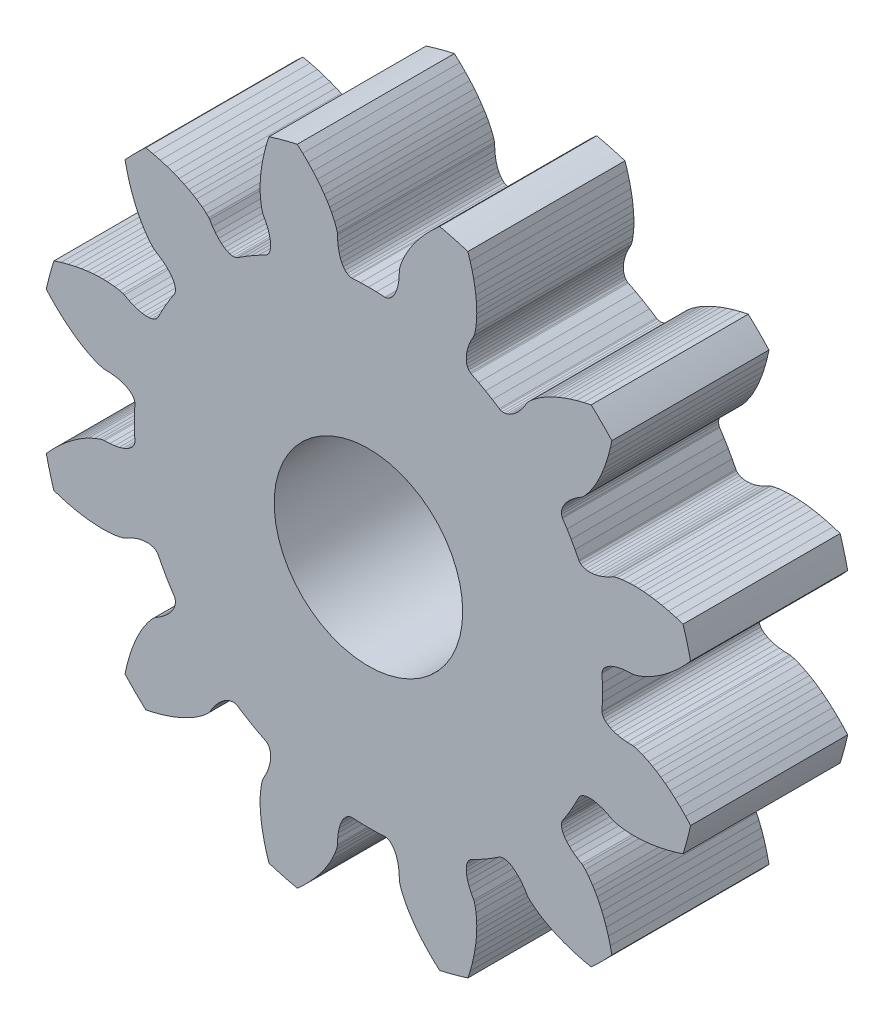
from build123d import *

# Parameters (mm, degrees)
SZKIC_R                     = 3
DODANIE_WYCI_GNI_CIE1_DEPTH = 5


with BuildPart() as part:
    # szkic → Dodanie-wyciągnięcie1 (new body)
    with BuildSketch(Plane.XY):
        with BuildLine():
            Line((13.3041035, -6.8561363), (13.3646303, -6.6242917))
            Line((13.3646303, -6.6242917), (13.4304655, -6.4093816))
            Line((13.4304655, -6.4093816), (13.5002922, -6.2114851))
            Line((13.5002922, -6.2114851), (13.5727071, -6.0307313))
            Line((13.5727071, -6.0307313), (13.646359, -5.8670802))
            Line((13.646359, -5.8670802), (13.721124, -5.718017))
            Line((13.721124, -5.718017), (13.7934881, -5.5876952))
            Line((13.7934881, -5.5876952), (13.8641894, -5.4719934))
            Line((13.8641894, -5.4719934), (13.993399, -5.287051))
            Line((13.993399, -5.287051), (14.1005731, -5.157982))
            Line((14.1005731, -5.157982), (14.1765304, -5.080584))
            Line((14.1765304, -5.080584), (14.2152558, -5.0521983))
            Line((14.2152558, -5.0521983), (14.3621288, -4.9615699))
            Line((14.3621288, -4.9615699), (14.4896324, -4.8681526))
            Line((14.4896324, -4.8681526), (14.5978226, -4.7734035))
            Line((14.5978226, -4.7734035), (14.6868312, -4.6787708))
            Line((14.6868312, -4.6787708), (14.7568878, -4.5856924))
            Line((14.7568878, -4.5856924), (14.8083, -4.495561))
            Line((14.8083, -4.495561), (14.8414711, -4.409795))
            Line((14.8414711, -4.409795), (14.8568795, -4.3297232))
            Line((14.8568795, -4.3297232), (14.8550807, -4.2566876))
            Line((14.8550807, -4.2566876), (14.8367255, -4.1919755))
            Line((14.8367255, -4.1919755), (14.821549, -4.163129))
            Line((14.821549, -4.163129), (14.6787997, -3.9427598))
            Line((14.6787997, -3.9427598), (14.5481107, -3.725))
            Line((14.5481107, -3.725), (14.4248697, -3.5029402))
            Line((14.4248697, -3.5029402), (14.305399, -3.269131))
            Line((14.305399, -3.269131), (14.2880055, -3.2415645))
            Line((14.2880055, -3.2415645), (14.2411407, -3.1933124))
            Line((14.2411407, -3.1933124), (14.1787895, -3.1552368))
            Line((14.1787895, -3.1552368), (14.1017411, -3.128545))
            Line((14.1017411, -3.128545), (14.01088, -3.114389))
            Line((14.01088, -3.114389), (13.9071178, -3.1138476))
            Line((13.9071178, -3.1138476), (13.7914812, -3.1279792))
            Line((13.7914812, -3.1279792), (13.6650226, -3.1577465))
            Line((13.6650226, -3.1577465), (13.5288724, -3.2040674))
            Line((13.5288724, -3.2040674), (13.3842188, -3.2677801))
            Line((13.3842188, -3.2677801), (13.2322958, -3.3496617))
            Line((13.2322958, -3.3496617), (13.1883504, -3.369006))
            Line((13.1883504, -3.369006), (13.0833431, -3.396088))
            Line((13.0833431, -3.396088), (12.917979, -3.424369))
            Line((12.917979, -3.424369), (12.6932094, -3.4437966))
            Line((12.6932094, -3.4437966), (12.5576581, -3.4471748))
            Line((12.5576581, -3.4471748), (12.408614, -3.444683))
            Line((12.408614, -3.444683), (12.242139, -3.4348998))
            Line((12.242139, -3.4348998), (12.0635871, -3.4168587))
            Line((12.0635871, -3.4168587), (11.8708422, -3.3891949))
            Line((11.8708422, -3.3891949), (11.6645455, -3.3507184))
            Line((11.6645455, -3.3507184), (11.4455103, -3.3002783))
            Line((11.4455103, -3.3002783), (11.2144635, -3.2367737))
            Line((11.2144635, -3.2367737), (10.9882086, -3.1643386))
            ThreePointArc((10.9882086, -3.1643386), (10.857824593, -2.717587715), (10.747365, -2.2654981))
            Line((10.747365, -2.2654981), (10.90709, -2.08964))
            Line((10.90709, -2.08964), (11.07543, -1.91912))
            Line((11.07543, -1.91912), (11.2399, -1.76592))
            Line((11.2399, -1.76592), (11.39932, -1.62945))
            Line((11.39932, -1.62945), (11.55241, -1.50912))
            Line((11.55241, -1.50912), (11.69802, -1.40422))
            Line((11.69802, -1.40422), (11.8373, -1.31251))
            Line((11.8373, -1.31251), (11.96513, -1.23583))
            Line((11.96513, -1.23583), (12.08421, -1.17098))
            Line((12.08421, -1.17098), (12.28858, -1.07542))
            Line((12.28858, -1.07542), (12.44593, -1.01723))
            Line((12.44593, -1.01723), (12.55041, -0.98818))
            Line((12.55041, -0.98818), (12.59814, -0.98296))
            Line((12.59814, -0.98296), (12.77065, -0.97791))
            Line((12.77065, -0.97791), (12.92778, -0.96076))
            Line((12.92778, -0.96076), (13.06885, -0.9328))
            Line((13.06885, -0.9328), (13.19325, -0.89535))
            Line((13.19325, -0.89535), (13.30046, -0.84977))
            Line((13.30046, -0.84977), (13.39005, -0.79742))
            Line((13.39005, -0.79742), (13.46166, -0.73973))
            Line((13.46166, -0.73973), (13.51504, -0.67809))
            Line((13.51504, -0.67809), (13.55, -0.61394))
            Line((13.55, -0.61394), (13.56646, -0.54872))
            Line((13.56646, -0.54872), (13.56774, -0.51615))
            Line((13.56774, -0.51615), (13.5543, -0.25393))
            Line((13.5543, -0.25393), (13.55, 0))
            Line((13.55, 0), (13.5543, 0.25393))
            Line((13.5543, 0.25393), (13.56774, 0.51615))
            Line((13.56774, 0.51615), (13.56646, 0.54872))
            Line((13.56646, 0.54872), (13.55, 0.61394))
            Line((13.55, 0.61394), (13.51504, 0.67809))
            Line((13.51504, 0.67809), (13.46166, 0.73973))
            Line((13.46166, 0.73973), (13.39005, 0.79742))
            Line((13.39005, 0.79742), (13.30046, 0.84977))
            Line((13.30046, 0.84977), (13.19325, 0.89535))
            Line((13.19325, 0.89535), (13.06885, 0.9328))
            Line((13.06885, 0.9328), (12.92778, 0.96076))
            Line((12.92778, 0.96076), (12.77065, 0.97791))
            Line((12.77065, 0.97791), (12.59814, 0.98296))
            Line((12.59814, 0.98296), (12.55041, 0.98818))
            Line((12.55041, 0.98818), (12.44593, 1.01723))
            Line((12.44593, 1.01723), (12.28858, 1.07542))
            Line((12.28858, 1.07542), (12.08421, 1.17098))
            Line((12.08421, 1.17098), (11.96513, 1.23583))
            Line((11.96513, 1.23583), (11.8373, 1.31251))
            Line((11.8373, 1.31251), (11.69802, 1.40422))
            Line((11.69802, 1.40422), (11.55241, 1.50912))
            Line((11.55241, 1.50912), (11.39932, 1.62945))
            Line((11.39932, 1.62945), (11.2399, 1.76592))
            Line((11.2399, 1.76592), (11.07543, 1.91912))
            Line((11.07543, 1.91912), (10.90709, 2.08964))
            Line((10.90709, 2.08964), (10.747365, 2.2654981))
            ThreePointArc((10.747365, 2.2654981), (10.857824593, 2.717587715), (10.9882086, 3.1643386))
            Line((10.9882086, 3.1643386), (11.2144635, 3.2367737))
            Line((11.2144635, 3.2367737), (11.4455103, 3.3002783))
            Line((11.4455103, 3.3002783), (11.6645455, 3.3507184))
            Line((11.6645455, 3.3507184), (11.8708422, 3.3891949))
            Line((11.8708422, 3.3891949), (12.0635871, 3.4168587))
            Line((12.0635871, 3.4168587), (12.242139, 3.4348998))
            Line((12.242139, 3.4348998), (12.408614, 3.444683))
            Line((12.408614, 3.444683), (12.5576581, 3.4471748))
            Line((12.5576581, 3.4471748), (12.6932094, 3.4437966))
            Line((12.6932094, 3.4437966), (12.917979, 3.424369))
            Line((12.917979, 3.424369), (13.0833431, 3.396088))
            Line((13.0833431, 3.396088), (13.1883504, 3.369006))
            Line((13.1883504, 3.369006), (13.2322958, 3.3496617))
            Line((13.2322958, 3.3496617), (13.3842188, 3.2677801))
            Line((13.3842188, 3.2677801), (13.5288724, 3.2040674))
            Line((13.5288724, 3.2040674), (13.6650226, 3.1577465))
            Line((13.6650226, 3.1577465), (13.7914812, 3.1279792))
            Line((13.7914812, 3.1279792), (13.9071178, 3.1138476))
            Line((13.9071178, 3.1138476), (14.01088, 3.114389))
            Line((14.01088, 3.114389), (14.1017411, 3.128545))
            Line((14.1017411, 3.128545), (14.1787895, 3.1552368))
            Line((14.1787895, 3.1552368), (14.2411407, 3.1933124))
            Line((14.2411407, 3.1933124), (14.2880055, 3.2415645))
            Line((14.2880055, 3.2415645), (14.305399, 3.269131))
            Line((14.305399, 3.269131), (14.4248697, 3.5029402))
            Line((14.4248697, 3.5029402), (14.5481107, 3.725))
            Line((14.5481107, 3.725), (14.6787997, 3.9427598))
            Line((14.6787997, 3.9427598), (14.821549, 4.163129))
            Line((14.821549, 4.163129), (14.8367255, 4.1919755))
            Line((14.8367255, 4.1919755), (14.8550807, 4.2566876))
            Line((14.8550807, 4.2566876), (14.8568795, 4.3297232))
            Line((14.8568795, 4.3297232), (14.8414711, 4.409795))
            Line((14.8414711, 4.409795), (14.8083, 4.495561))
            Line((14.8083, 4.495561), (14.7568878, 4.5856924))
            Line((14.7568878, 4.5856924), (14.6868312, 4.6787708))
            Line((14.6868312, 4.6787708), (14.5978226, 4.7734035))
            Line((14.5978226, 4.7734035), (14.4896324, 4.8681526))
            Line((14.4896324, 4.8681526), (14.3621288, 4.9615699))
            Line((14.3621288, 4.9615699), (14.2152558, 5.0521983))
            Line((14.2152558, 5.0521983), (14.1765304, 5.080584))
            Line((14.1765304, 5.080584), (14.1005731, 5.157982))
            Line((14.1005731, 5.157982), (13.993399, 5.287051))
            Line((13.993399, 5.287051), (13.8641894, 5.4719934))
            Line((13.8641894, 5.4719934), (13.7934881, 5.5876952))
            Line((13.7934881, 5.5876952), (13.721124, 5.718017))
            Line((13.721124, 5.718017), (13.646359, 5.8670802))
            Line((13.646359, 5.8670802), (13.5727071, 6.0307313))
            Line((13.5727071, 6.0307313), (13.5002922, 6.2114851))
            Line((13.5002922, 6.2114851), (13.4304655, 6.4093816))
            Line((13.4304655, 6.4093816), (13.3646303, 6.6242917))
            Line((13.3646303, 6.6242917), (13.3041035, 6.8561363))
            Line((13.3041035, 6.8561363), (13.2537067, 7.0882964))
            ThreePointArc((13.2537067, 7.0882964), (13.575412309, 7.424587691), (13.9117036, 7.7462933))
            Line((13.9117036, 7.7462933), (14.1438637, 7.6958965))
            Line((14.1438637, 7.6958965), (14.3757083, 7.6353697))
            Line((14.3757083, 7.6353697), (14.5906184, 7.5695345))
            Line((14.5906184, 7.5695345), (14.7885149, 7.4997078))
            Line((14.7885149, 7.4997078), (14.9692687, 7.4272929))
            Line((14.9692687, 7.4272929), (15.1329198, 7.353641))
            Line((15.1329198, 7.353641), (15.281983, 7.278876))
            Line((15.281983, 7.278876), (15.4123048, 7.2065119))
            Line((15.4123048, 7.2065119), (15.5280066, 7.1358106))
            Line((15.5280066, 7.1358106), (15.712949, 7.006601))
            Line((15.712949, 7.006601), (15.842018, 6.8994269))
            Line((15.842018, 6.8994269), (15.919416, 6.8234696))
            Line((15.919416, 6.8234696), (15.9478017, 6.7847442))
            Line((15.9478017, 6.7847442), (16.0384301, 6.6378712))
            Line((16.0384301, 6.6378712), (16.1318474, 6.5103676))
            Line((16.1318474, 6.5103676), (16.2265965, 6.4021774))
            Line((16.2265965, 6.4021774), (16.3212292, 6.3131688))
            Line((16.3212292, 6.3131688), (16.4143076, 6.2431122))
            Line((16.4143076, 6.2431122), (16.504439, 6.1917))
            Line((16.504439, 6.1917), (16.590205, 6.1585289))
            Line((16.590205, 6.1585289), (16.6702768, 6.1431205))
            Line((16.6702768, 6.1431205), (16.7433124, 6.1449193))
            Line((16.7433124, 6.1449193), (16.8080245, 6.1632745))
            Line((16.8080245, 6.1632745), (16.836871, 6.178451))
            Line((16.836871, 6.178451), (17.0572402, 6.3212003))
            Line((17.0572402, 6.3212003), (17.275, 6.4518893))
            Line((17.275, 6.4518893), (17.4970598, 6.5751303))
            Line((17.4970598, 6.5751303), (17.730869, 6.694601))
            Line((17.730869, 6.694601), (17.7584355, 6.7119945))
            Line((17.7584355, 6.7119945), (17.8066876, 6.7588593))
            Line((17.8066876, 6.7588593), (17.8447632, 6.8212105))
            Line((17.8447632, 6.8212105), (17.871455, 6.8982589))
            Line((17.871455, 6.8982589), (17.885611, 6.98912))
            Line((17.885611, 6.98912), (17.8861524, 7.0928822))
            Line((17.8861524, 7.0928822), (17.8720208, 7.2085188))
            Line((17.8720208, 7.2085188), (17.8422535, 7.3349774))
            Line((17.8422535, 7.3349774), (17.7959326, 7.4711276))
            Line((17.7959326, 7.4711276), (17.7322199, 7.6157812))
            Line((17.7322199, 7.6157812), (17.6503383, 7.7677042))
            Line((17.6503383, 7.7677042), (17.630994, 7.8116496))
            Line((17.630994, 7.8116496), (17.603912, 7.9166569))
            Line((17.603912, 7.9166569), (17.575631, 8.082021))
            Line((17.575631, 8.082021), (17.5562034, 8.3067906))
            Line((17.5562034, 8.3067906), (17.5528252, 8.4423419))
            Line((17.5528252, 8.4423419), (17.555317, 8.591386))
            Line((17.555317, 8.591386), (17.5651002, 8.757861))
            Line((17.5651002, 8.757861), (17.5831413, 8.9364129))
            Line((17.5831413, 8.9364129), (17.6108051, 9.1291578))
            Line((17.6108051, 9.1291578), (17.6492816, 9.3354545))
            Line((17.6492816, 9.3354545), (17.6997217, 9.5544897))
            Line((17.6997217, 9.5544897), (17.7632263, 9.7855365))
            Line((17.7632263, 9.7855365), (17.8356614, 10.0117914))
            ThreePointArc((17.8356614, 10.0117914), (18.282412285, 10.142175407), (18.7345019, 10.252635))
            Line((18.7345019, 10.252635), (18.91036, 10.09291))
            Line((18.91036, 10.09291), (19.08088, 9.92457))
            Line((19.08088, 9.92457), (19.23408, 9.7601))
            Line((19.23408, 9.7601), (19.37055, 9.60068))
            Line((19.37055, 9.60068), (19.49088, 9.44759))
            Line((19.49088, 9.44759), (19.59578, 9.30198))
            Line((19.59578, 9.30198), (19.68749, 9.1627))
            Line((19.68749, 9.1627), (19.76417, 9.03487))
            Line((19.76417, 9.03487), (19.82902, 8.91579))
            Line((19.82902, 8.91579), (19.92458, 8.71142))
            Line((19.92458, 8.71142), (19.98277, 8.55407))
            Line((19.98277, 8.55407), (20.01182, 8.44959))
            Line((20.01182, 8.44959), (20.01704, 8.40186))
            Line((20.01704, 8.40186), (20.02209, 8.22935))
            Line((20.02209, 8.22935), (20.03924, 8.07222))
            Line((20.03924, 8.07222), (20.0672, 7.93115))
            Line((20.0672, 7.93115), (20.10465, 7.80675))
            Line((20.10465, 7.80675), (20.15023, 7.69954))
            Line((20.15023, 7.69954), (20.20258, 7.60995))
            Line((20.20258, 7.60995), (20.26027, 7.53834))
            Line((20.26027, 7.53834), (20.32191, 7.48496))
            Line((20.32191, 7.48496), (20.38606, 7.45))
            Line((20.38606, 7.45), (20.45128, 7.43354))
            Line((20.45128, 7.43354), (20.48385, 7.43226))
            Line((20.48385, 7.43226), (20.74607, 7.4457))
            Line((20.74607, 7.4457), (21, 7.45))
            Line((21, 7.45), (21.25393, 7.4457))
            Line((21.25393, 7.4457), (21.51615, 7.43226))
            Line((21.51615, 7.43226), (21.54872, 7.43354))
            Line((21.54872, 7.43354), (21.61394, 7.45))
            Line((21.61394, 7.45), (21.67809, 7.48496))
            Line((21.67809, 7.48496), (21.73973, 7.53834))
            Line((21.73973, 7.53834), (21.79742, 7.60995))
            Line((21.79742, 7.60995), (21.84977, 7.69954))
            Line((21.84977, 7.69954), (21.89535, 7.80675))
            Line((21.89535, 7.80675), (21.9328, 7.93115))
            Line((21.9328, 7.93115), (21.96076, 8.07222))
            Line((21.96076, 8.07222), (21.97791, 8.22935))
            Line((21.97791, 8.22935), (21.98296, 8.40186))
            Line((21.98296, 8.40186), (21.98818, 8.44959))
            Line((21.98818, 8.44959), (22.01723, 8.55407))
            Line((22.01723, 8.55407), (22.07542, 8.71142))
            Line((22.07542, 8.71142), (22.17098, 8.91579))
            Line((22.17098, 8.91579), (22.23583, 9.03487))
            Line((22.23583, 9.03487), (22.31251, 9.1627))
            Line((22.31251, 9.1627), (22.40422, 9.30198))
            Line((22.40422, 9.30198), (22.50912, 9.44759))
            Line((22.50912, 9.44759), (22.62945, 9.60068))
            Line((22.62945, 9.60068), (22.76592, 9.7601))
            Line((22.76592, 9.7601), (22.91912, 9.92457))
            Line((22.91912, 9.92457), (23.08964, 10.09291))
            Line((23.08964, 10.09291), (23.2654981, 10.252635))
            ThreePointArc((23.2654981, 10.252635), (23.717587715, 10.142175407), (24.1643386, 10.0117914))
            Line((24.1643386, 10.0117914), (24.2367737, 9.7855365))
            Line((24.2367737, 9.7855365), (24.3002783, 9.5544897))
            Line((24.3002783, 9.5544897), (24.3507184, 9.3354545))
            Line((24.3507184, 9.3354545), (24.3891949, 9.1291578))
            Line((24.3891949, 9.1291578), (24.4168587, 8.9364129))
            Line((24.4168587, 8.9364129), (24.4348998, 8.757861))
            Line((24.4348998, 8.757861), (24.444683, 8.591386))
            Line((24.444683, 8.591386), (24.4471748, 8.4423419))
            Line((24.4471748, 8.4423419), (24.4437966, 8.3067906))
            Line((24.4437966, 8.3067906), (24.424369, 8.082021))
            Line((24.424369, 8.082021), (24.396088, 7.9166569))
            Line((24.396088, 7.9166569), (24.369006, 7.8116496))
            Line((24.369006, 7.8116496), (24.3496617, 7.7677042))
            Line((24.3496617, 7.7677042), (24.2677801, 7.6157812))
            Line((24.2677801, 7.6157812), (24.2040674, 7.4711276))
            Line((24.2040674, 7.4711276), (24.1577465, 7.3349774))
            Line((24.1577465, 7.3349774), (24.1279792, 7.2085188))
            Line((24.1279792, 7.2085188), (24.1138476, 7.0928822))
            Line((24.1138476, 7.0928822), (24.114389, 6.98912))
            Line((24.114389, 6.98912), (24.128545, 6.8982589))
            Line((24.128545, 6.8982589), (24.1552368, 6.8212105))
            Line((24.1552368, 6.8212105), (24.1933124, 6.7588593))
            Line((24.1933124, 6.7588593), (24.2415645, 6.7119945))
            Line((24.2415645, 6.7119945), (24.269131, 6.694601))
            Line((24.269131, 6.694601), (24.5029402, 6.5751303))
            Line((24.5029402, 6.5751303), (24.725, 6.4518893))
            Line((24.725, 6.4518893), (24.9427598, 6.3212003))
            Line((24.9427598, 6.3212003), (25.163129, 6.178451))
            Line((25.163129, 6.178451), (25.1919755, 6.1632745))
            Line((25.1919755, 6.1632745), (25.2566876, 6.1449193))
            Line((25.2566876, 6.1449193), (25.3297232, 6.1431205))
            Line((25.3297232, 6.1431205), (25.409795, 6.1585289))
            Line((25.409795, 6.1585289), (25.495561, 6.1917))
            Line((25.495561, 6.1917), (25.5856924, 6.2431122))
            Line((25.5856924, 6.2431122), (25.6787708, 6.3131688))
            Line((25.6787708, 6.3131688), (25.7734035, 6.4021774))
            Line((25.7734035, 6.4021774), (25.8681526, 6.5103676))
            Line((25.8681526, 6.5103676), (25.9615699, 6.6378712))
            Line((25.9615699, 6.6378712), (26.0521983, 6.7847442))
            Line((26.0521983, 6.7847442), (26.080584, 6.8234696))
            Line((26.080584, 6.8234696), (26.157982, 6.8994269))
            Line((26.157982, 6.8994269), (26.287051, 7.006601))
            Line((26.287051, 7.006601), (26.4719934, 7.1358106))
            Line((26.4719934, 7.1358106), (26.5876952, 7.2065119))
            Line((26.5876952, 7.2065119), (26.718017, 7.278876))
            Line((26.718017, 7.278876), (26.8670802, 7.353641))
            Line((26.8670802, 7.353641), (27.0307313, 7.4272929))
            Line((27.0307313, 7.4272929), (27.2114851, 7.4997078))
            Line((27.2114851, 7.4997078), (27.4093816, 7.5695345))
            Line((27.4093816, 7.5695345), (27.6242917, 7.6353697))
            Line((27.6242917, 7.6353697), (27.8561363, 7.6958965))
            Line((27.8561363, 7.6958965), (28.0882964, 7.7462933))
            ThreePointArc((28.0882964, 7.7462933), (28.424587691, 7.424587691), (28.7462933, 7.0882964))
            Line((28.7462933, 7.0882964), (28.6958965, 6.8561363))
            Line((28.6958965, 6.8561363), (28.6353697, 6.6242917))
            Line((28.6353697, 6.6242917), (28.5695345, 6.4093816))
            Line((28.5695345, 6.4093816), (28.4997078, 6.2114851))
            Line((28.4997078, 6.2114851), (28.4272929, 6.0307313))
            Line((28.4272929, 6.0307313), (28.353641, 5.8670802))
            Line((28.353641, 5.8670802), (28.278876, 5.718017))
            Line((28.278876, 5.718017), (28.2065119, 5.5876952))
            Line((28.2065119, 5.5876952), (28.1358106, 5.4719934))
            Line((28.1358106, 5.4719934), (28.006601, 5.287051))
            Line((28.006601, 5.287051), (27.8994269, 5.157982))
            Line((27.8994269, 5.157982), (27.8234696, 5.080584))
            Line((27.8234696, 5.080584), (27.7847442, 5.0521983))
            Line((27.7847442, 5.0521983), (27.6378712, 4.9615699))
            Line((27.6378712, 4.9615699), (27.5103676, 4.8681526))
            Line((27.5103676, 4.8681526), (27.4021774, 4.7734035))
            Line((27.4021774, 4.7734035), (27.3131688, 4.6787708))
            Line((27.3131688, 4.6787708), (27.2431122, 4.5856924))
            Line((27.2431122, 4.5856924), (27.1917, 4.495561))
            Line((27.1917, 4.495561), (27.1585289, 4.409795))
            Line((27.1585289, 4.409795), (27.1431205, 4.3297232))
            Line((27.1431205, 4.3297232), (27.1449193, 4.2566876))
            Line((27.1449193, 4.2566876), (27.1632745, 4.1919755))
            Line((27.1632745, 4.1919755), (27.178451, 4.163129))
            Line((27.178451, 4.163129), (27.3212003, 3.9427598))
            Line((27.3212003, 3.9427598), (27.4518893, 3.725))
            Line((27.4518893, 3.725), (27.5751303, 3.5029402))
            Line((27.5751303, 3.5029402), (27.694601, 3.269131))
            Line((27.694601, 3.269131), (27.7119945, 3.2415645))
            Line((27.7119945, 3.2415645), (27.7588593, 3.1933124))
            Line((27.7588593, 3.1933124), (27.8212105, 3.1552368))
            Line((27.8212105, 3.1552368), (27.8982589, 3.128545))
            Line((27.8982589, 3.128545), (27.98912, 3.114389))
            Line((27.98912, 3.114389), (28.0928822, 3.1138476))
            Line((28.0928822, 3.1138476), (28.2085188, 3.1279792))
            Line((28.2085188, 3.1279792), (28.3349774, 3.1577465))
            Line((28.3349774, 3.1577465), (28.4711276, 3.2040674))
            Line((28.4711276, 3.2040674), (28.6157812, 3.2677801))
            Line((28.6157812, 3.2677801), (28.7677042, 3.3496617))
            Line((28.7677042, 3.3496617), (28.8116496, 3.369006))
            Line((28.8116496, 3.369006), (28.9166569, 3.396088))
            Line((28.9166569, 3.396088), (29.082021, 3.424369))
            Line((29.082021, 3.424369), (29.3067906, 3.4437966))
            Line((29.3067906, 3.4437966), (29.4423419, 3.4471748))
            Line((29.4423419, 3.4471748), (29.591386, 3.444683))
            Line((29.591386, 3.444683), (29.757861, 3.4348998))
            Line((29.757861, 3.4348998), (29.9364129, 3.4168587))
            Line((29.9364129, 3.4168587), (30.1291578, 3.3891949))
            Line((30.1291578, 3.3891949), (30.3354545, 3.3507184))
            Line((30.3354545, 3.3507184), (30.5544897, 3.3002783))
            Line((30.5544897, 3.3002783), (30.7855365, 3.2367737))
            Line((30.7855365, 3.2367737), (31.0117914, 3.1643386))
            ThreePointArc((31.0117914, 3.1643386), (31.142175407, 2.717587715), (31.252635, 2.2654981))
            Line((31.252635, 2.2654981), (31.09291, 2.08964))
            Line((31.09291, 2.08964), (30.92457, 1.91912))
            Line((30.92457, 1.91912), (30.7601, 1.76592))
            Line((30.7601, 1.76592), (30.60068, 1.62945))
            Line((30.60068, 1.62945), (30.44759, 1.50912))
            Line((30.44759, 1.50912), (30.30198, 1.40422))
            Line((30.30198, 1.40422), (30.1627, 1.31251))
            Line((30.1627, 1.31251), (30.03487, 1.23583))
            Line((30.03487, 1.23583), (29.91579, 1.17098))
            Line((29.91579, 1.17098), (29.71142, 1.07542))
            Line((29.71142, 1.07542), (29.55407, 1.01723))
            Line((29.55407, 1.01723), (29.44959, 0.98818))
            Line((29.44959, 0.98818), (29.40186, 0.98296))
            Line((29.40186, 0.98296), (29.22935, 0.97791))
            Line((29.22935, 0.97791), (29.07222, 0.96076))
            Line((29.07222, 0.96076), (28.93115, 0.9328))
            Line((28.93115, 0.9328), (28.80675, 0.89535))
            Line((28.80675, 0.89535), (28.69954, 0.84977))
            Line((28.69954, 0.84977), (28.60995, 0.79742))
            Line((28.60995, 0.79742), (28.53834, 0.73973))
            Line((28.53834, 0.73973), (28.48496, 0.67809))
            Line((28.48496, 0.67809), (28.45, 0.61394))
            Line((28.45, 0.61394), (28.43354, 0.54872))
            Line((28.43354, 0.54872), (28.43226, 0.51615))
            Line((28.43226, 0.51615), (28.4457, 0.25393))
            Line((28.4457, 0.25393), (28.45, 0))
            Line((28.45, 0), (28.4457, -0.25393))
            Line((28.4457, -0.25393), (28.43226, -0.51615))
            Line((28.43226, -0.51615), (28.43354, -0.54872))
            Line((28.43354, -0.54872), (28.45, -0.61394))
            Line((28.45, -0.61394), (28.48496, -0.67809))
            Line((28.48496, -0.67809), (28.53834, -0.73973))
            Line((28.53834, -0.73973), (28.60995, -0.79742))
            Line((28.60995, -0.79742), (28.69954, -0.84977))
            Line((28.69954, -0.84977), (28.80675, -0.89535))
            Line((28.80675, -0.89535), (28.93115, -0.9328))
            Line((28.93115, -0.9328), (29.07222, -0.96076))
            Line((29.07222, -0.96076), (29.22935, -0.97791))
            Line((29.22935, -0.97791), (29.40186, -0.98296))
            Line((29.40186, -0.98296), (29.44959, -0.98818))
            Line((29.44959, -0.98818), (29.55407, -1.01723))
            Line((29.55407, -1.01723), (29.71142, -1.07542))
            Line((29.71142, -1.07542), (29.91579, -1.17098))
            Line((29.91579, -1.17098), (30.03487, -1.23583))
            Line((30.03487, -1.23583), (30.1627, -1.31251))
            Line((30.1627, -1.31251), (30.30198, -1.40422))
            Line((30.30198, -1.40422), (30.44759, -1.50912))
            Line((30.44759, -1.50912), (30.60068, -1.62945))
            Line((30.60068, -1.62945), (30.7601, -1.76592))
            Line((30.7601, -1.76592), (30.92457, -1.91912))
            Line((30.92457, -1.91912), (31.09291, -2.08964))
            Line((31.09291, -2.08964), (31.252635, -2.2654981))
            ThreePointArc((31.252635, -2.2654981), (31.142175407, -2.717587715), (31.0117914, -3.1643386))
            Line((31.0117914, -3.1643386), (30.7855365, -3.2367737))
            Line((30.7855365, -3.2367737), (30.5544897, -3.3002783))
            Line((30.5544897, -3.3002783), (30.3354545, -3.3507184))
            Line((30.3354545, -3.3507184), (30.1291578, -3.3891949))
            Line((30.1291578, -3.3891949), (29.9364129, -3.4168587))
            Line((29.9364129, -3.4168587), (29.757861, -3.4348998))
            Line((29.757861, -3.4348998), (29.591386, -3.444683))
            Line((29.591386, -3.444683), (29.4423419, -3.4471748))
            Line((29.4423419, -3.4471748), (29.3067906, -3.4437966))
            Line((29.3067906, -3.4437966), (29.082021, -3.424369))
            Line((29.082021, -3.424369), (28.9166569, -3.396088))
            Line((28.9166569, -3.396088), (28.8116496, -3.369006))
            Line((28.8116496, -3.369006), (28.7677042, -3.3496617))
            Line((28.7677042, -3.3496617), (28.6157812, -3.2677801))
            Line((28.6157812, -3.2677801), (28.4711276, -3.2040674))
            Line((28.4711276, -3.2040674), (28.3349774, -3.1577465))
            Line((28.3349774, -3.1577465), (28.2085188, -3.1279792))
            Line((28.2085188, -3.1279792), (28.0928822, -3.1138476))
            Line((28.0928822, -3.1138476), (27.98912, -3.114389))
            Line((27.98912, -3.114389), (27.8982589, -3.128545))
            Line((27.8982589, -3.128545), (27.8212105, -3.1552368))
            Line((27.8212105, -3.1552368), (27.7588593, -3.1933124))
            Line((27.7588593, -3.1933124), (27.7119945, -3.2415645))
            Line((27.7119945, -3.2415645), (27.694601, -3.269131))
            Line((27.694601, -3.269131), (27.5751303, -3.5029402))
            Line((27.5751303, -3.5029402), (27.4518893, -3.725))
            Line((27.4518893, -3.725), (27.3212003, -3.9427598))
            Line((27.3212003, -3.9427598), (27.178451, -4.163129))
            Line((27.178451, -4.163129), (27.1632745, -4.1919755))
            Line((27.1632745, -4.1919755), (27.1449193, -4.2566876))
            Line((27.1449193, -4.2566876), (27.1431205, -4.3297232))
            Line((27.1431205, -4.3297232), (27.1585289, -4.409795))
            Line((27.1585289, -4.409795), (27.1917, -4.495561))
            Line((27.1917, -4.495561), (27.2431122, -4.5856924))
            Line((27.2431122, -4.5856924), (27.3131688, -4.6787708))
            Line((27.3131688, -4.6787708), (27.4021774, -4.7734035))
            Line((27.4021774, -4.7734035), (27.5103676, -4.8681526))
            Line((27.5103676, -4.8681526), (27.6378712, -4.9615699))
            Line((27.6378712, -4.9615699), (27.7847442, -5.0521983))
            Line((27.7847442, -5.0521983), (27.8234696, -5.080584))
            Line((27.8234696, -5.080584), (27.8994269, -5.157982))
            Line((27.8994269, -5.157982), (28.006601, -5.287051))
            Line((28.006601, -5.287051), (28.1358106, -5.4719934))
            Line((28.1358106, -5.4719934), (28.2065119, -5.5876952))
            Line((28.2065119, -5.5876952), (28.278876, -5.718017))
            Line((28.278876, -5.718017), (28.353641, -5.8670802))
            Line((28.353641, -5.8670802), (28.4272929, -6.0307313))
            Line((28.4272929, -6.0307313), (28.4997078, -6.2114851))
            Line((28.4997078, -6.2114851), (28.5695345, -6.4093816))
            Line((28.5695345, -6.4093816), (28.6353697, -6.6242917))
            Line((28.6353697, -6.6242917), (28.6958965, -6.8561363))
            Line((28.6958965, -6.8561363), (28.7462933, -7.0882964))
            ThreePointArc((28.7462933, -7.0882964), (28.424587691, -7.424587691), (28.0882964, -7.7462933))
            Line((28.0882964, -7.7462933), (27.8561363, -7.6958965))
            Line((27.8561363, -7.6958965), (27.6242917, -7.6353697))
            Line((27.6242917, -7.6353697), (27.4093816, -7.5695345))
            Line((27.4093816, -7.5695345), (27.2114851, -7.4997078))
            Line((27.2114851, -7.4997078), (27.0307313, -7.4272929))
            Line((27.0307313, -7.4272929), (26.8670802, -7.353641))
            Line((26.8670802, -7.353641), (26.718017, -7.278876))
            Line((26.718017, -7.278876), (26.5876952, -7.2065119))
            Line((26.5876952, -7.2065119), (26.4719934, -7.1358106))
            Line((26.4719934, -7.1358106), (26.287051, -7.006601))
            Line((26.287051, -7.006601), (26.157982, -6.8994269))
            Line((26.157982, -6.8994269), (26.080584, -6.8234696))
            Line((26.080584, -6.8234696), (26.0521983, -6.7847442))
            Line((26.0521983, -6.7847442), (25.9615699, -6.6378712))
            Line((25.9615699, -6.6378712), (25.8681526, -6.5103676))
            Line((25.8681526, -6.5103676), (25.7734035, -6.4021774))
            Line((25.7734035, -6.4021774), (25.6787708, -6.3131688))
            Line((25.6787708, -6.3131688), (25.5856924, -6.2431122))
            Line((25.5856924, -6.2431122), (25.495561, -6.1917))
            Line((25.495561, -6.1917), (25.409795, -6.1585289))
            Line((25.409795, -6.1585289), (25.3297232, -6.1431205))
            Line((25.3297232, -6.1431205), (25.2566876, -6.1449193))
            Line((25.2566876, -6.1449193), (25.1919755, -6.1632745))
            Line((25.1919755, -6.1632745), (25.163129, -6.178451))
            Line((25.163129, -6.178451), (24.9427598, -6.3212003))
            Line((24.9427598, -6.3212003), (24.725, -6.4518893))
            Line((24.725, -6.4518893), (24.5029402, -6.5751303))
            Line((24.5029402, -6.5751303), (24.269131, -6.694601))
            Line((24.269131, -6.694601), (24.2415645, -6.7119945))
            Line((24.2415645, -6.7119945), (24.1933124, -6.7588593))
            Line((24.1933124, -6.7588593), (24.1552368, -6.8212105))
            Line((24.1552368, -6.8212105), (24.128545, -6.8982589))
            Line((24.128545, -6.8982589), (24.114389, -6.98912))
            Line((24.114389, -6.98912), (24.1138476, -7.0928822))
            Line((24.1138476, -7.0928822), (24.1279792, -7.2085188))
            Line((24.1279792, -7.2085188), (24.1577465, -7.3349774))
            Line((24.1577465, -7.3349774), (24.2040674, -7.4711276))
            Line((24.2040674, -7.4711276), (24.2677801, -7.6157812))
            Line((24.2677801, -7.6157812), (24.3496617, -7.7677042))
            Line((24.3496617, -7.7677042), (24.369006, -7.8116496))
            Line((24.369006, -7.8116496), (24.396088, -7.9166569))
            Line((24.396088, -7.9166569), (24.424369, -8.082021))
            Line((24.424369, -8.082021), (24.4437966, -8.3067906))
            Line((24.4437966, -8.3067906), (24.4471748, -8.4423419))
            Line((24.4471748, -8.4423419), (24.444683, -8.591386))
            Line((24.444683, -8.591386), (24.4348998, -8.757861))
            Line((24.4348998, -8.757861), (24.4168587, -8.9364129))
            Line((24.4168587, -8.9364129), (24.3891949, -9.1291578))
            Line((24.3891949, -9.1291578), (24.3507184, -9.3354545))
            Line((24.3507184, -9.3354545), (24.3002783, -9.5544897))
            Line((24.3002783, -9.5544897), (24.2367737, -9.7855365))
            Line((24.2367737, -9.7855365), (24.1643386, -10.0117914))
            ThreePointArc((24.1643386, -10.0117914), (23.717587715, -10.142175407), (23.2654981, -10.252635))
            Line((23.2654981, -10.252635), (23.08964, -10.09291))
            Line((23.08964, -10.09291), (22.91912, -9.92457))
            Line((22.91912, -9.92457), (22.76592, -9.7601))
            Line((22.76592, -9.7601), (22.62945, -9.60068))
            Line((22.62945, -9.60068), (22.50912, -9.44759))
            Line((22.50912, -9.44759), (22.40422, -9.30198))
            Line((22.40422, -9.30198), (22.31251, -9.1627))
            Line((22.31251, -9.1627), (22.23583, -9.03487))
            Line((22.23583, -9.03487), (22.17098, -8.91579))
            Line((22.17098, -8.91579), (22.07542, -8.71142))
            Line((22.07542, -8.71142), (22.01723, -8.55407))
            Line((22.01723, -8.55407), (21.98818, -8.44959))
            Line((21.98818, -8.44959), (21.98296, -8.40186))
            Line((21.98296, -8.40186), (21.97791, -8.22935))
            Line((21.97791, -8.22935), (21.96076, -8.07222))
            Line((21.96076, -8.07222), (21.9328, -7.93115))
            Line((21.9328, -7.93115), (21.89535, -7.80675))
            Line((21.89535, -7.80675), (21.84977, -7.69954))
            Line((21.84977, -7.69954), (21.79742, -7.60995))
            Line((21.79742, -7.60995), (21.73973, -7.53834))
            Line((21.73973, -7.53834), (21.67809, -7.48496))
            Line((21.67809, -7.48496), (21.61394, -7.45))
            Line((21.61394, -7.45), (21.54872, -7.43354))
            Line((21.54872, -7.43354), (21.51615, -7.43226))
            Line((21.51615, -7.43226), (21.25393, -7.4457))
            Line((21.25393, -7.4457), (21, -7.45))
            Line((21, -7.45), (20.74607, -7.4457))
            Line((20.74607, -7.4457), (20.48385, -7.43226))
            Line((20.48385, -7.43226), (20.45128, -7.43354))
            Line((20.45128, -7.43354), (20.38606, -7.45))
            Line((20.38606, -7.45), (20.32191, -7.48496))
            Line((20.32191, -7.48496), (20.26027, -7.53834))
            Line((20.26027, -7.53834), (20.20258, -7.60995))
            Line((20.20258, -7.60995), (20.15023, -7.69954))
            Line((20.15023, -7.69954), (20.10465, -7.80675))
            Line((20.10465, -7.80675), (20.0672, -7.93115))
            Line((20.0672, -7.93115), (20.03924, -8.07222))
            Line((20.03924, -8.07222), (20.02209, -8.22935))
            Line((20.02209, -8.22935), (20.01704, -8.40186))
            Line((20.01704, -8.40186), (20.01182, -8.44959))
            Line((20.01182, -8.44959), (19.98277, -8.55407))
            Line((19.98277, -8.55407), (19.92458, -8.71142))
            Line((19.92458, -8.71142), (19.82902, -8.91579))
            Line((19.82902, -8.91579), (19.76417, -9.03487))
            Line((19.76417, -9.03487), (19.68749, -9.1627))
            Line((19.68749, -9.1627), (19.59578, -9.30198))
            Line((19.59578, -9.30198), (19.49088, -9.44759))
            Line((19.49088, -9.44759), (19.37055, -9.60068))
            Line((19.37055, -9.60068), (19.23408, -9.7601))
            Line((19.23408, -9.7601), (19.08088, -9.92457))
            Line((19.08088, -9.92457), (18.91036, -10.09291))
            Line((18.91036, -10.09291), (18.7345019, -10.252635))
            ThreePointArc((18.7345019, -10.252635), (18.282412285, -10.142175407), (17.8356614, -10.0117914))
            Line((17.8356614, -10.0117914), (17.7632263, -9.7855365))
            Line((17.7632263, -9.7855365), (17.6997217, -9.5544897))
            Line((17.6997217, -9.5544897), (17.6492816, -9.3354545))
            Line((17.6492816, -9.3354545), (17.6108051, -9.1291578))
            Line((17.6108051, -9.1291578), (17.5831413, -8.9364129))
            Line((17.5831413, -8.9364129), (17.5651002, -8.757861))
            Line((17.5651002, -8.757861), (17.555317, -8.591386))
            Line((17.555317, -8.591386), (17.5528252, -8.4423419))
            Line((17.5528252, -8.4423419), (17.5562034, -8.3067906))
            Line((17.5562034, -8.3067906), (17.575631, -8.082021))
            Line((17.575631, -8.082021), (17.603912, -7.9166569))
            Line((17.603912, -7.9166569), (17.630994, -7.8116496))
            Line((17.630994, -7.8116496), (17.6503383, -7.7677042))
            Line((17.6503383, -7.7677042), (17.7322199, -7.6157812))
            Line((17.7322199, -7.6157812), (17.7959326, -7.4711276))
            Line((17.7959326, -7.4711276), (17.8422535, -7.3349774))
            Line((17.8422535, -7.3349774), (17.8720208, -7.2085188))
            Line((17.8720208, -7.2085188), (17.8861524, -7.0928822))
            Line((17.8861524, -7.0928822), (17.885611, -6.98912))
            Line((17.885611, -6.98912), (17.871455, -6.8982589))
            Line((17.871455, -6.8982589), (17.8447632, -6.8212105))
            Line((17.8447632, -6.8212105), (17.8066876, -6.7588593))
            Line((17.8066876, -6.7588593), (17.7584355, -6.7119945))
            Line((17.7584355, -6.7119945), (17.730869, -6.694601))
            Line((17.730869, -6.694601), (17.4970598, -6.5751303))
            Line((17.4970598, -6.5751303), (17.275, -6.4518893))
            Line((17.275, -6.4518893), (17.0572402, -6.3212003))
            Line((17.0572402, -6.3212003), (16.836871, -6.178451))
            Line((16.836871, -6.178451), (16.8080245, -6.1632745))
            Line((16.8080245, -6.1632745), (16.7433124, -6.1449193))
            Line((16.7433124, -6.1449193), (16.6702768, -6.1431205))
            Line((16.6702768, -6.1431205), (16.590205, -6.1585289))
            Line((16.590205, -6.1585289), (16.504439, -6.1917))
            Line((16.504439, -6.1917), (16.4143076, -6.2431122))
            Line((16.4143076, -6.2431122), (16.3212292, -6.3131688))
            Line((16.3212292, -6.3131688), (16.2265965, -6.4021774))
            Line((16.2265965, -6.4021774), (16.1318474, -6.5103676))
            Line((16.1318474, -6.5103676), (16.0384301, -6.6378712))
            Line((16.0384301, -6.6378712), (15.9478017, -6.7847442))
            Line((15.9478017, -6.7847442), (15.919416, -6.8234696))
            Line((15.919416, -6.8234696), (15.842018, -6.8994269))
            Line((15.842018, -6.8994269), (15.712949, -7.006601))
            Line((15.712949, -7.006601), (15.5280066, -7.1358106))
            Line((15.5280066, -7.1358106), (15.4123048, -7.2065119))
            Line((15.4123048, -7.2065119), (15.281983, -7.278876))
            Line((15.281983, -7.278876), (15.1329198, -7.353641))
            Line((15.1329198, -7.353641), (14.9692687, -7.4272929))
            Line((14.9692687, -7.4272929), (14.7885149, -7.4997078))
            Line((14.7885149, -7.4997078), (14.5906184, -7.5695345))
            Line((14.5906184, -7.5695345), (14.3757083, -7.6353697))
            Line((14.3757083, -7.6353697), (14.1438637, -7.6958965))
            Line((14.1438637, -7.6958965), (13.9117036, -7.7462933))
            ThreePointArc((13.9117036, -7.7462933), (13.575412309, -7.424587691), (13.2537067, -7.0882964))
            Line((13.2537067, -7.0882964), (13.3041035, -6.8561363))
        make_face()
        with Locations((21, 0)):
            Circle(SZKIC_R, mode=Mode.SUBTRACT)
    extrude(amount=DODANIE_WYCI_GNI_CIE1_DEPTH)


solid = part.part
